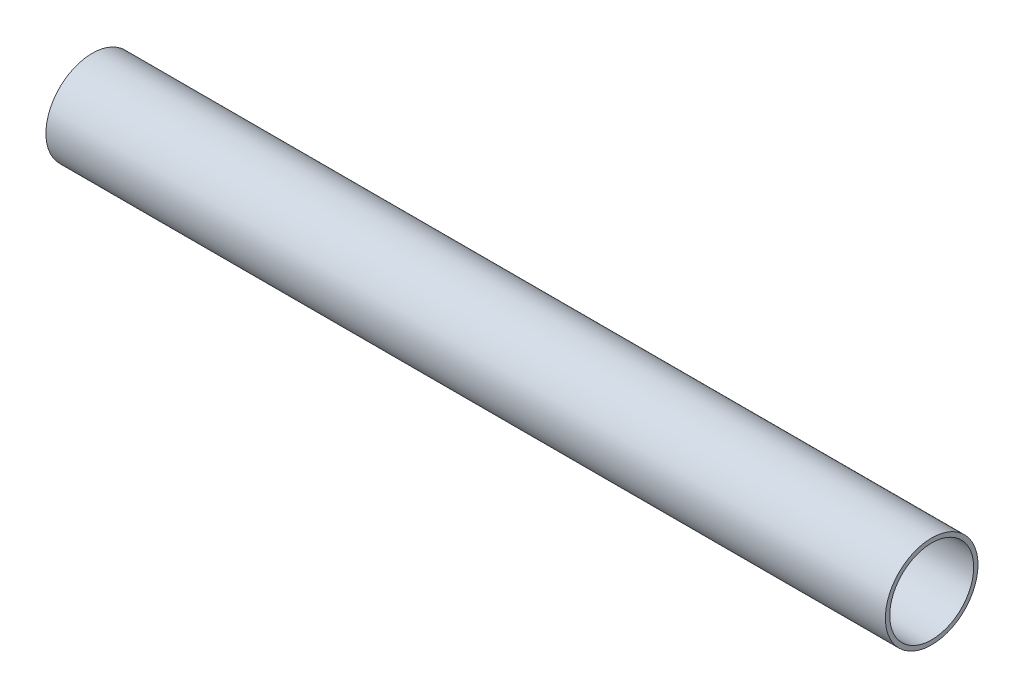
from build123d import *

# Parameters (mm, degrees)
SKETCH1_W = 145
SKETCH1_H = 0.75


with BuildPart() as part:
    # Sketch1 → Revolve1 (revolve)
    with BuildSketch(Plane.XY):
        with Locations((72.5, 7.625)):
            Rectangle(SKETCH1_W, SKETCH1_H)
    revolve(axis=Axis((0, 0, 0), (1, 0, 0)))


solid = part.part
